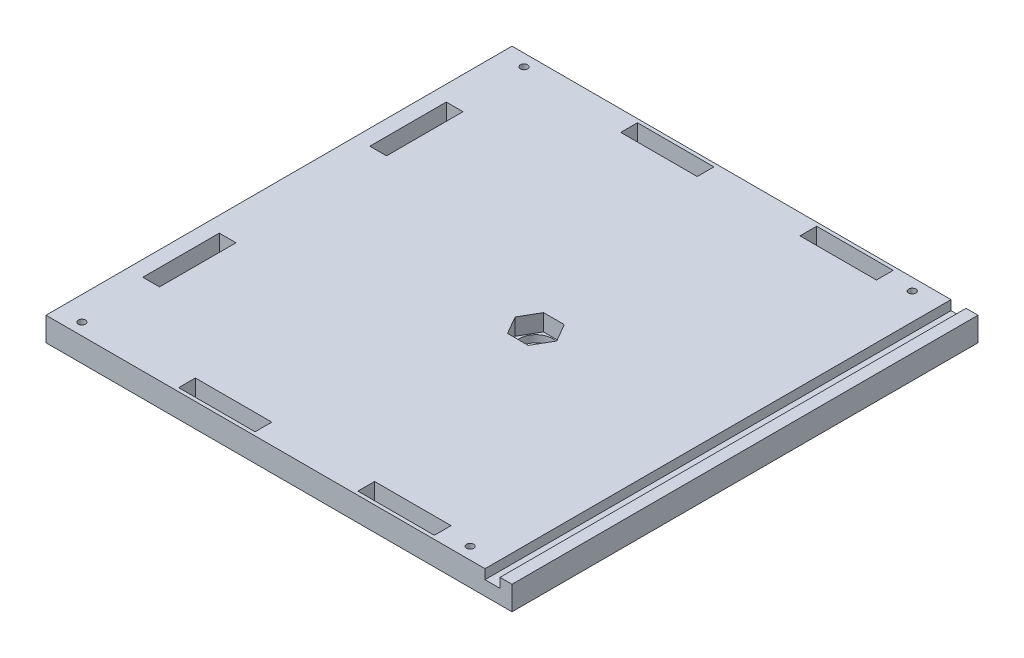
from build123d import *

# Parameters (mm, degrees)
ESBO_O1_W                = 195
ESBO_O1_H                = 195
RESSALTO_EXTRUS_O1_DEPTH = 10
ESBO_O2_W                = 7
ESBO_O2_H                = 32
ESBO_O2_W_2              = 32
ESBO_O2_H_2              = 7
CORTE_EXTRUS_O1_DEPTH    = 11
ESBO_O3_W                = 6.3
ESBO_O3_H                = 195
CORTE_EXTRUS_O2_DEPTH    = 4
ESBO_O4_R                = 1.5
CORTE_EXTRUS_O3_DEPTH    = 11
ESBO_O5_R                = 1.5
CORTE_EXTRUS_O4_DEPTH    = 11
ESBO_O6_R                = 7
CORTE_EXTRUS_O5_DEPTH    = 11
ESBO_O7_R                = 7
CORTE_EXTRUS_O6_DEPTH    = 7


with BuildPart() as part:
    # Esboço1 → Ressalto-extrusão1 (new body)
    with BuildSketch(Plane(origin=(0, 0, 0), x_dir=(1, 0, 0), z_dir=(0, 1, 0))):
        Rectangle(ESBO_O1_W, ESBO_O1_H)
    extrude(amount=RESSALTO_EXTRUS_O1_DEPTH)

    # Esboço2 → Corte-extrusão1 (cut, through all)
    with BuildSketch(Plane(origin=(0, 10, 0), x_dir=(1, 0, 0), z_dir=(0, 1, 0))):
        with Locations((-87.5, 47.5)):
            Rectangle(ESBO_O2_W, ESBO_O2_H)
        with Locations((-87.5, -47.5)):
            Rectangle(ESBO_O2_W, ESBO_O2_H)
        with Locations((-27.5, -92.5)):
            Rectangle(ESBO_O2_W_2, ESBO_O2_H_2)
        with Locations((47.5, -92.5)):
            Rectangle(ESBO_O2_W_2, ESBO_O2_H_2)
        with Locations((47.5, 92.5)):
            Rectangle(ESBO_O2_W_2, ESBO_O2_H_2)
        with Locations((-27.5, 92.5)):
            Rectangle(ESBO_O2_W_2, ESBO_O2_H_2)
    extrude(amount=-CORTE_EXTRUS_O1_DEPTH, mode=Mode.SUBTRACT)

    # Esboço3 → Corte-extrusão2 (cut)
    with BuildSketch(Plane(origin=(0, 10, 0), x_dir=(1, 0, 0), z_dir=(0, 1, 0))):
        with Locations((89.35, 0)):
            Rectangle(ESBO_O3_W, ESBO_O3_H)
    extrude(amount=-CORTE_EXTRUS_O2_DEPTH, mode=Mode.SUBTRACT)

    # Esboço4 → Corte-extrusão3 (cut, through all)
    with BuildSketch(Plane.XZ):
        with Locations((-87.5, 92.5)):
            Circle(ESBO_O4_R)
        with Locations((-87.5, -92.5)):
            Circle(ESBO_O4_R)
    extrude(amount=-CORTE_EXTRUS_O3_DEPTH, mode=Mode.SUBTRACT)

    # Esboço5 → Corte-extrusão4 (cut, through all)
    with BuildSketch(Plane.XZ):
        with Locations((75, 92.5)):
            Circle(ESBO_O5_R)
        with Locations((75, -92.5)):
            Circle(ESBO_O5_R)
    extrude(amount=-CORTE_EXTRUS_O4_DEPTH, mode=Mode.SUBTRACT)

    # Esboço6 → Corte-extrusão5 (cut, through all)
    with BuildSketch(Plane.XZ):
        with Locations((10, 0)):
            Circle(ESBO_O6_R)
    extrude(amount=-CORTE_EXTRUS_O5_DEPTH, mode=Mode.SUBTRACT)

    # Esboço7 → Corte-extrusão6 (cut)
    with BuildSketch(Plane(origin=(0, 10, 0), x_dir=(1, 0, 0), z_dir=(0, 1, 0))):
        Polygon((14.35, 7.534421013), (18.7, 0), (14.35, -7.534421013), (5.65, -7.534421013), (1.3, 0), (5.65, 7.534421013), align=None)
        with Locations((10, 0)):
            Circle(ESBO_O7_R, mode=Mode.SUBTRACT)
        with Locations((10, 0)):
            Circle(ESBO_O7_R)
    extrude(amount=-CORTE_EXTRUS_O6_DEPTH, mode=Mode.SUBTRACT)


solid = part.part
